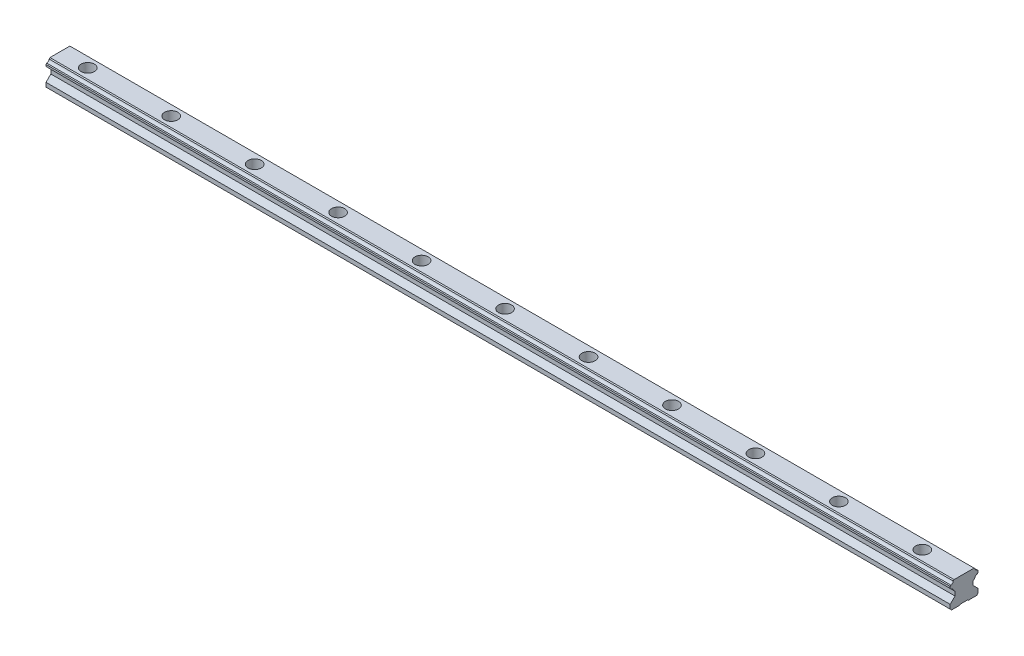
from build123d import *

# Parameters (mm, degrees)
BOSS_EXTRUDE1_DEPTH = 650
LPATTERN1_COUNT     = 9
LPATTERN1_PITCH     = 60


with BuildPart() as part:
    # Sketch1 → Boss-Extrude1 (new body)
    with BuildSketch(Plane(origin=(-20, 0, 0), x_dir=(0, 0, -1), z_dir=(1, 0, 0))):
        with BuildLine():
            Line((-10, 4.000077248), (-10, 1))
            Line((-10, 1), (-9, 0))
            Line((-9, 0), (-3, 0))
            Line((-3, 0), (-2.5, 0.5))
            Line((-2.5, 0.5), (2.5, 0.5))
            Line((2.5, 0.5), (3, 0))
            Line((3, 0), (9, 0))
            Line((9, 0), (10, 1))
            Line((10, 1), (10, 4.000077248))
            Line((10, 4.000077248), (6.550048828, 7.449951172))
            Line((6.550048828, 7.449951172), (6.550048828, 10.379235268))
            Line((6.550048828, 10.379235268), (7.765945541, 11.595131504))
            ThreePointArc((7.765945541, 11.595131504), (8.344873878, 12.735447983), (9.485190198, 13.314376637))
            Line((9.485190198, 13.314376637), (10, 13.82918644))
            Line((10, 13.82918644), (10, 15.160037041))
            Line((10, 15.160037041), (9.472673258, 15.687363783))
            ThreePointArc((9.472673258, 15.687363783), (8.344874488, 16.264307267), (7.767930373, 17.392105714))
            Line((7.767930373, 17.392105714), (7.160036564, 18))
            Line((7.160036564, 18), (-7.160036564, 18))
            Line((-7.160036564, 18), (-7.767930373, 17.392105714))
            ThreePointArc((-7.767930373, 17.392105714), (-8.344874488, 16.264307267), (-9.472673258, 15.687363783))
            Line((-9.472673258, 15.687363783), (-10, 15.160037041))
            Line((-10, 15.160037041), (-10, 13.82918644))
            Line((-10, 13.82918644), (-9.485190198, 13.314376637))
            ThreePointArc((-9.485190198, 13.314376637), (-8.344873878, 12.735447983), (-7.765945541, 11.595131504))
            Line((-7.765945541, 11.595131504), (-6.550048828, 10.379235268))
            Line((-6.550048828, 10.379235268), (-6.550048828, 7.449951172))
            Line((-6.550048828, 7.449951172), (-10, 4.000077248))
        make_face()
    extrude(amount=BOSS_EXTRUDE1_DEPTH)

    # Sketch2 → Cut-Revolve1 (revolve, cut)
    with BuildSketch(Plane.XY):
        Polygon((0, 18), (4.75, 18), (4.75, 9.5), (3, 9.5), (3, 0), (0, 0), align=None)
    revolve(axis=Axis((0, 0, 0), (0, 1, 0)), mode=Mode.SUBTRACT)

    # Sketch3 → Cut-Revolve2 (revolve, cut)
    with BuildSketch(Plane.XY):
        Polygon((60, 18), (64.75, 18), (64.75, 9.5), (63, 9.5), (63, 0), (60, 0), align=None)
    revolve(axis=Axis((60, 0, 0), (0, 1, 0)), mode=Mode.SUBTRACT)

    # Sketch4 → Cut-Revolve3 (revolve, cut)
    with BuildSketch(Plane.XY):
        Polygon((120, 18), (124.75, 18), (124.75, 9.5), (123, 9.5), (123, 0), (120, 0), align=None)
    cut_revolve3 = revolve(axis=Axis((120, 0, 0), (0, 1, 0)), mode=Mode.SUBTRACT)

    # LPattern1: Cut-Revolve3 ×9
    with Locations(*[(i * LPATTERN1_PITCH, 0, 0) for i in range(1, LPATTERN1_COUNT)]):
        add(cut_revolve3, mode=Mode.SUBTRACT)


solid = part.part
